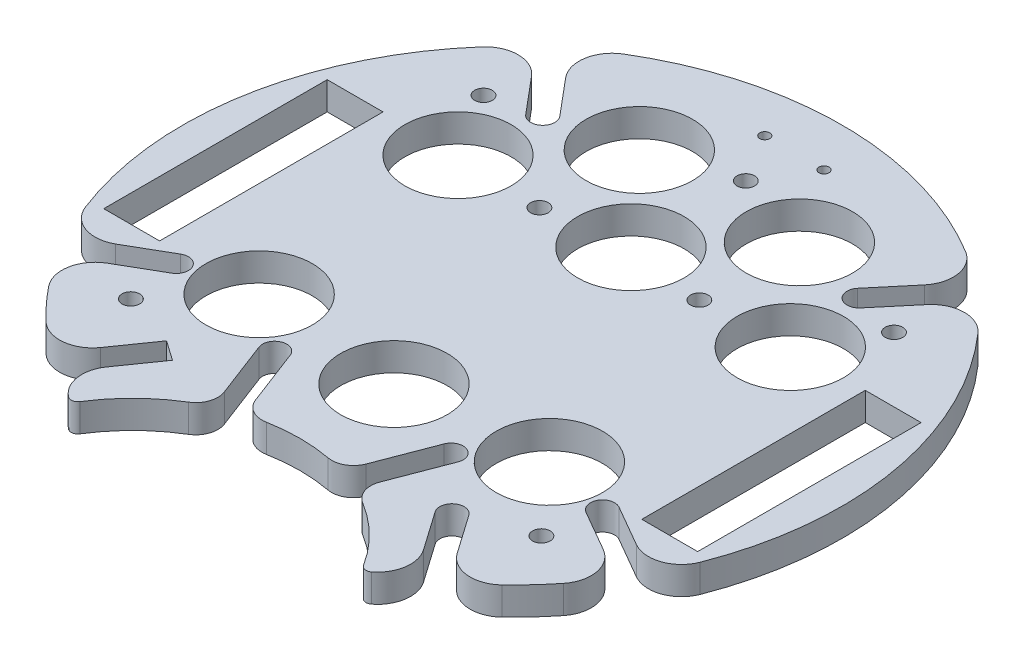
from build123d import *

# Parameters (mm, degrees)
SKETCH1_R           = 2
SKETCH1_W           = 12.7
SKETCH1_H           = 50.8
SKETCH1_R_2         = 12.095
SKETCH1_R_3         = 12.075
SKETCH1_R_4         = 1.143
BOSS_EXTRUDE1_DEPTH = 6.35
SKETCH5_R           = 2.75
CUT_EXTRUDE5_DEPTH  = 10


with BuildPart() as part:
    # Sketch1 → Boss-Extrude1 (new body)
    with BuildSketch(Plane(origin=(0, 0, 0), x_dir=(1, 0, 0), z_dir=(0, 1, 0))):
        with BuildLine():
            Line((-40.520093651, -53.074212293), (-34.358059191, -44.273915061))
            Line((-34.358059191, -44.273915061), (-29.852722948, -47.428585461))
            Line((-29.852722948, -47.428585461), (-36.014757408, -56.228882693))
            ThreePointArc((-36.014757408, -56.228882693), (-37.282182463, -61.682274385), (-34.419720881, -66.493943628))
            ThreePointArc((-34.419720881, -66.493943628), (-33.243515234, -66.777434912), (-32.240681933, -66.10056535))
            ThreePointArc((-32.240681933, -66.10056535), (-26.728650164, -59.250774979), (-19.793246149, -53.846860332))
            ThreePointArc((-19.793246149, -53.846860332), (-17.659799789, -51.192486841), (-17.721018114, -47.787557426))
            Line((-17.721018114, -47.787557426), (-22.618223277, -34.99005566))
            Line((-22.618223277, -34.99005566), (-17.481479686, -33.024383946))
            Line((-17.481479686, -33.024383946), (-12.584274523, -45.821885712))
            ThreePointArc((-12.584274523, -45.821885712), (-10.356790186, -48.397852623), (-6.996351286, -48.949887413))
            ThreePointArc((-6.996351286, -48.949887413), (0, -48.302004425), (6.996351286, -48.949887413))
            ThreePointArc((6.996351286, -48.949887413), (10.356790186, -48.397852623), (12.584274523, -45.821885712))
            Line((12.584274523, -45.821885712), (17.481479686, -33.024383946))
            Line((17.481479686, -33.024383946), (22.618223277, -34.99005566))
            Line((22.618223277, -34.99005566), (17.721018114, -47.787557426))
            ThreePointArc((17.721018114, -47.787557426), (17.659799789, -51.192486841), (19.793246149, -53.846860332))
            ThreePointArc((19.793246149, -53.846860332), (26.728650164, -59.250774979), (32.240681933, -66.10056535))
            ThreePointArc((32.240681933, -66.10056535), (33.243515234, -66.777434912), (34.419720881, -66.493943628))
            ThreePointArc((34.419720881, -66.493943628), (37.282182463, -61.682274385), (36.014757408, -56.228882693))
            Line((36.014757408, -56.228882693), (29.852722948, -47.428585461))
            Line((29.852722948, -47.428585461), (34.358059191, -44.273915061))
            Line((34.358059191, -44.273915061), (40.520093651, -53.074212293))
            ThreePointArc((40.520093651, -53.074212293), (45.927580176, -56.23617342), (51.848593315, -54.191543356))
            ThreePointArc((51.848593315, -54.191543356), (55.295899374, -50.669157408), (58.504414423, -46.927960674))
            ThreePointArc((58.504414423, -46.927960674), (60.030901261, -40.882046302), (56.458030011, -35.771485305))
            Line((56.458030011, -35.771485305), (56.349654942, -35.70891493))
            Line((56.349654942, -35.70891493), (47.078155187, -30.35601205))
            Line((47.078155187, -30.35601205), (49.828155187, -25.59287233))
            Line((49.828155187, -25.59287233), (59.099654942, -30.945775209))
            Line((59.099654942, -30.945775209), (59.208030011, -31.008345585))
            ThreePointArc((59.208030011, -31.008345585), (65.420341286, -31.547262353), (69.893013303, -27.202328787))
            ThreePointArc((69.893013303, -27.202328787), (73.860606951, 13.023468848), (56.374397975, 49.466425512))
            ThreePointArc((56.374397975, 49.466425512), (50.654117331, 52.01932544), (44.991624855, 49.340690033))
            Line((44.991624855, 49.340690033), (38.069871869, 41.091666046))
            Line((38.069871869, 41.091666046), (33.856627432, 44.626997899))
            Line((33.856627432, 44.626997899), (40.778380417, 52.876021886))
            ThreePointArc((40.778380417, 52.876021886), (42.433039833, 58.917628536), (38.925607882, 64.107698843))
            ThreePointArc((38.925607882, 64.107698843), (0, 75), (-38.925607882, 64.107698843))
            ThreePointArc((-38.925607882, 64.107698843), (-42.433039833, 58.917628536), (-40.778380417, 52.876021886))
            Line((-40.778380417, 52.876021886), (-33.856627432, 44.626997899))
            Line((-33.856627432, 44.626997899), (-38.069871869, 41.091666046))
            Line((-38.069871869, 41.091666046), (-44.991624855, 49.340690033))
            ThreePointArc((-44.991624855, 49.340690033), (-50.654117331, 52.01932544), (-56.374397975, 49.466425512))
            ThreePointArc((-56.374397975, 49.466425512), (-73.860606951, 13.023468848), (-69.893013303, -27.202328787))
            ThreePointArc((-69.893013303, -27.202328787), (-65.420341286, -31.547262353), (-59.208030011, -31.008345585))
            Line((-59.208030011, -31.008345585), (-59.099654942, -30.945775209))
            Line((-59.099654942, -30.945775209), (-49.828155187, -25.59287233))
            Line((-49.828155187, -25.59287233), (-47.078155187, -30.35601205))
            Line((-47.078155187, -30.35601205), (-56.349654942, -35.70891493))
            Line((-56.349654942, -35.70891493), (-56.458030011, -35.771485305))
            ThreePointArc((-56.458030011, -35.771485305), (-60.030901261, -40.882046302), (-58.504414423, -46.927960674))
            ThreePointArc((-58.504414423, -46.927960674), (-55.295899374, -50.669157408), (-51.848593315, -54.191543356))
            ThreePointArc((-51.848593315, -54.191543356), (-45.927580176, -56.23617342), (-40.520093651, -53.074212293))
        make_face()
        with Locations((-46.663733983, -40.081231883)):
            Circle(SKETCH1_R, mode=Mode.SUBTRACT)
        with Locations((-61.164123727, 0)):
            Rectangle(SKETCH1_W, SKETCH1_H, mode=Mode.SUBTRACT)
        with Locations((-32.995567884, -24.592872328)):
            Circle(SKETCH1_R_2, mode=Mode.SUBTRACT)
        with Locations((46.663733983, -40.081231883)):
            Circle(SKETCH1_R, mode=Mode.SUBTRACT)
        with Locations((0, -26.93833729)):
            Circle(SKETCH1_R_2, mode=Mode.SUBTRACT)
        with Locations((32.995567884, -24.592872328)):
            Circle(SKETCH1_R_2, mode=Mode.SUBTRACT)
        with Locations((61.164123727, 0)):
            Rectangle(SKETCH1_W, SKETCH1_H, mode=Mode.SUBTRACT)
        with Locations((-37.772386793, 25.4)):
            Circle(SKETCH1_R_3, mode=Mode.SUBTRACT)
        with Locations((-18.178952795, 24.310551096)):
            Circle(SKETCH1_R, mode=Mode.SUBTRACT)
        with Locations((-46.663733983, 40.081231883)):
            Circle(SKETCH1_R, mode=Mode.SUBTRACT)
        with Locations((-18.1962694, 47.045805056)):
            Circle(SKETCH1_R_2, mode=Mode.SUBTRACT)
        with Locations((-6.731, 64.107698843)):
            Circle(SKETCH1_R_4, mode=Mode.SUBTRACT)
        with Locations((0, 26.93833729)):
            Circle(SKETCH1_R_2, mode=Mode.SUBTRACT)
        with Locations((18.178952795, 24.310551096)):
            Circle(SKETCH1_R, mode=Mode.SUBTRACT)
        with Locations((37.772386793, 25.4)):
            Circle(SKETCH1_R_2, mode=Mode.SUBTRACT)
        with Locations((18.1962694, 47.045805056)):
            Circle(SKETCH1_R_2, mode=Mode.SUBTRACT)
        with Locations((0, 53.061187965)):
            Circle(SKETCH1_R, mode=Mode.SUBTRACT)
        with Locations((6.731, 64.107698843)):
            Circle(SKETCH1_R_4, mode=Mode.SUBTRACT)
        with Locations((46.663733983, 40.081231883)):
            Circle(SKETCH1_R, mode=Mode.SUBTRACT)
    extrude(amount=BOSS_EXTRUDE1_DEPTH)

    # Sketch5 → Cut-Extrude5 (cut)
    with BuildSketch(Plane(origin=(0, 6.35, 0), x_dir=(1, 0, 0), z_dir=(0, 1, 0))):
        with Locations((-48.453155187, -27.97444219)):
            Circle(SKETCH5_R)
        with Locations((-20.049851481, -34.007219803)):
            Circle(SKETCH5_R)
        with Locations((20.049851481, -34.007219803)):
            Circle(SKETCH5_R)
        with Locations((32.105391069, -45.851250261)):
            Circle(SKETCH5_R)
        with Locations((48.453155187, -27.97444219)):
            Circle(SKETCH5_R)
        with Locations((35.963249651, 42.859331973)):
            Circle(SKETCH5_R)
        with Locations((-35.963249651, 42.859331973)):
            Circle(SKETCH5_R)
    extrude(amount=-CUT_EXTRUDE5_DEPTH, mode=Mode.SUBTRACT)


solid = part.part
